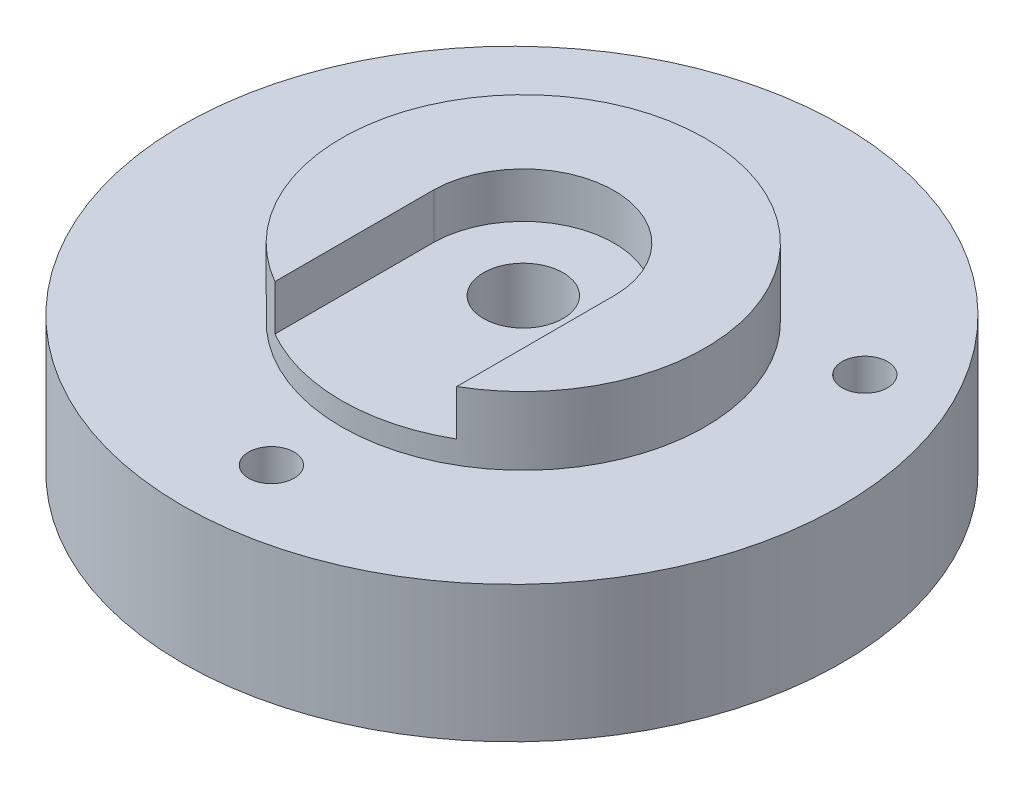
from build123d import *

# Parameters (mm, degrees)
SKETCH1_W              = 150
SKETCH1_H              = 30
SKETCH1_W_2            = 80
SKETCH1_H_2            = 15
BOSS_EXTRUDE1_DEPTH    = 145
CUT_EXTRUDE1_DEPTH     = 145
CUT_EXTRUDE2_DEPTH     = 15
CUT_EXTRUDE3_DEPTH     = 10
M20_TAPPED_HOLE1_D     = 17.5
M20_TAPPED_HOLE1_DEPTH = 40
M20_TAPPED_HOLE1_TIP   = 5.257530416
SKETCH7_R              = 5
CUT_EXTRUDE4_DEPTH     = 83
SKETCH8_R              = 55
CUT_EXTRUDE5_DEPTH     = 15


with BuildPart() as part:
    # Sketch1 → Boss-Extrude1 (new body)
    with BuildSketch(Plane.XY):
        with Locations((75, 15)):
            Rectangle(SKETCH1_W, SKETCH1_H)
        with Locations((75, 37.5)):
            Rectangle(SKETCH1_W_2, SKETCH1_H_2)
    extrude(amount=BOSS_EXTRUDE1_DEPTH)

    # Sketch2 → Cut-Extrude1 (cut)
    with BuildSketch(Plane(origin=(0, 0, 0), x_dir=(1, 0, 0), z_dir=(0, 1, 0))):
        with BuildLine():
            Line((72.5, 0), (0, 0))
            Line((0, 0), (0, -72.5))
            ThreePointArc((0, -72.5), (21.234758364, -21.234758364), (72.5, 0))
        make_face()
        with BuildLine():
            ThreePointArc((72.5, -145), (21.234758364, -123.765241636), (0, -72.5))
            Line((0, -72.5), (0, -145))
            Line((0, -145), (72.5, -145))
        make_face()
        with BuildLine():
            Line((150, 0), (72.5, 0))
            ThreePointArc((72.5, 0), (123.765241636, -21.234758364), (145, -72.5))
            ThreePointArc((145, -72.5), (123.765241636, -123.765241636), (72.5, -145))
            Line((72.5, -145), (150, -145))
            Line((150, -145), (150, 0))
        make_face()
    extrude(amount=CUT_EXTRUDE1_DEPTH, mode=Mode.SUBTRACT)

    # Sketch3 → Cut-Extrude2 (cut)
    with BuildSketch(Plane(origin=(0, 45, 0), x_dir=(1, 0, 0), z_dir=(0, 1, 0))):
        with BuildLine():
            ThreePointArc((115, -13.763299378), (75.498630618, -0.062038858), (35, -10.45163177))
            Line((35, -10.45163177), (35, -72.50163177))
            ThreePointArc((35, -72.50163177), (75, -32.50163177), (115, -72.50163177))
            Line((115, -72.50163177), (115, -13.763299378))
        make_face()
        with BuildLine():
            ThreePointArc((115, -72.50163177), (75, -112.50163177), (35, -72.50163177))
            Line((35, -72.50163177), (35, -134.54836823))
            ThreePointArc((35, -134.54836823), (75.498630618, -144.937961142), (115, -131.236700622))
            Line((115, -131.236700622), (115, -72.50163177))
        make_face()
    extrude(amount=-CUT_EXTRUDE2_DEPTH, mode=Mode.SUBTRACT)

    # Sketch4 → Cut-Extrude3 (cut)
    with BuildSketch(Plane(origin=(0, 45, 0), x_dir=(1, 0, 0), z_dir=(0, 1, 0))):
        with BuildLine():
            Line((55, -107.142647921), (55, -72.142647921))
            ThreePointArc((55, -72.142647921), (75, -52.498410294), (95, -72.142647921))
            Line((95, -72.142647921), (95, -107.142647921))
            ThreePointArc((95, -107.142647921), (75, -112.50163177), (55, -107.142647921))
        make_face()
    extrude(amount=-CUT_EXTRUDE3_DEPTH, mode=Mode.SUBTRACT)

    # M20 Tapped Hole1
    with Locations(Plane(origin=(75, 35, 72.50163177), x_dir=(0, 0, 1), z_dir=(0, 1, 0))):
        with Locations((0, 0)):
            Hole(M20_TAPPED_HOLE1_D / 2, depth=M20_TAPPED_HOLE1_DEPTH)
            with Locations((0, 0, -(M20_TAPPED_HOLE1_DEPTH + M20_TAPPED_HOLE1_TIP / 2))):  # 118° drill point
                Cone(0, M20_TAPPED_HOLE1_D / 2, M20_TAPPED_HOLE1_TIP, mode=Mode.SUBTRACT)

    # Sketch7 → Cut-Extrude4 (cut)
    with BuildSketch(Plane(origin=(0, 0, 0), x_dir=(1, 0, 0), z_dir=(0, 1, 0))):
        with Locations((74.583225581, -127.50163177)):
            Circle(SKETCH7_R)
        with Locations((27.368602792, -45.00163177)):
            Circle(SKETCH7_R)
        with Locations((122.631397208, -45.00163177)):
            Circle(SKETCH7_R)
    extrude(amount=CUT_EXTRUDE4_DEPTH, mode=Mode.SUBTRACT)

    # Sketch8 → Cut-Extrude5 (cut)
    with BuildSketch(Plane.XZ):
        with Locations((75, 72.50163177)):
            Circle(SKETCH8_R)
    extrude(amount=-CUT_EXTRUDE5_DEPTH, mode=Mode.SUBTRACT)


solid = part.part
